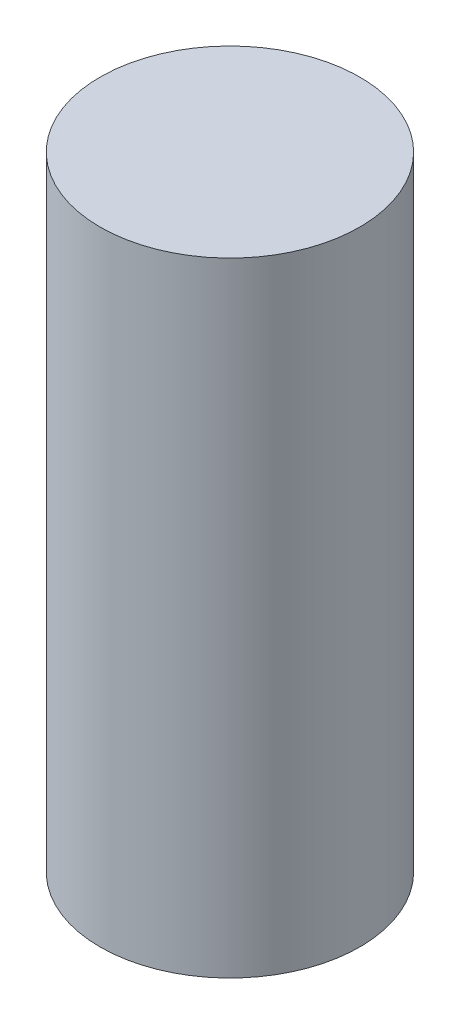
from build123d import *

# Parameters (mm, degrees)
SKETCH1_W = 1
SKETCH1_H = 4.8


with BuildPart() as part:
    # Sketch1 → Revolve1 (revolve)
    with BuildSketch(Plane.XY):
        with Locations((0.5, 13.725)):
            Rectangle(SKETCH1_W, SKETCH1_H)
    revolve(axis=Axis((0, -50, 0), (0, 1, 0)))


solid = part.part
